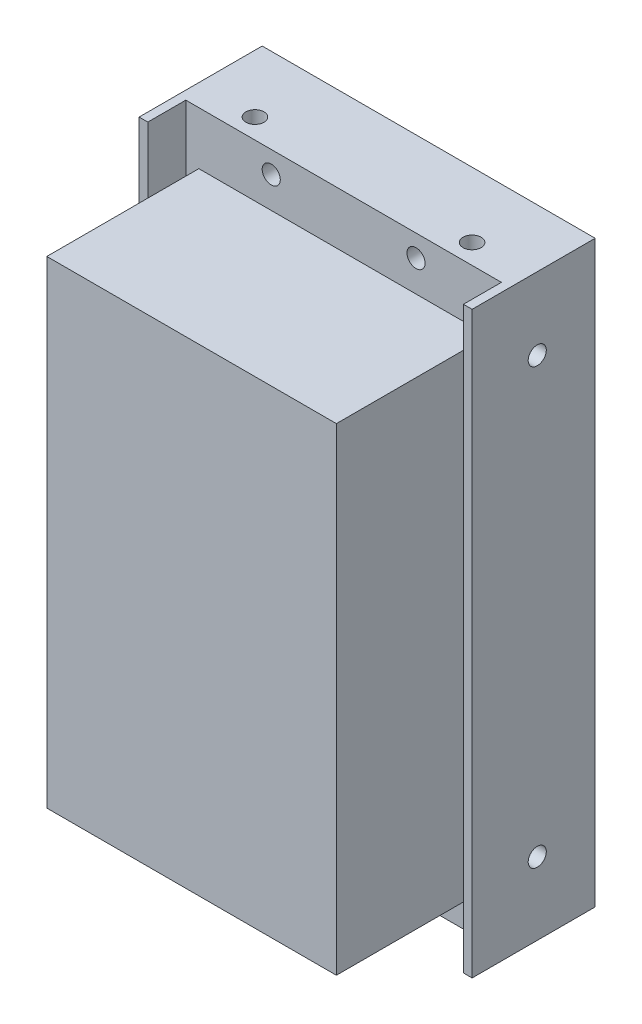
from build123d import *

# Parameters (mm, degrees)
SKETCH1_W                     = 46
SKETCH1_H                     = 11.75
BOSS_EXTRUDE1_DEPTH           = 80
SKETCH2_W                     = 1.2
SKETCH2_H                     = 5.25
BOSS_EXTRUDE2_DEPTH           = 80
SKETCH3_W                     = 40
SKETCH3_H                     = 66
CIRCUIT_BOARD_CLEARANCE_DEPTH = 21
M3X0_5_TAPPED_HOLE1_D         = 2.5
M3X0_5_TAPPED_HOLE2_D         = 2.5
M3X0_5_TAPPED_HOLE2_DEPTH     = 5
M3X0_5_TAPPED_HOLE2_TIP       = 0.751075774
M3X0_5_TAPPED_HOLE3_D         = 2.5


with BuildPart() as part:
    # Sketch1 → Boss-Extrude1 (new body)
    with BuildSketch(Plane(origin=(0, 0, 0), x_dir=(1, 0, 0), z_dir=(0, 1, 0))):
        with Locations((0, 5.875)):
            Rectangle(SKETCH1_W, SKETCH1_H)
    extrude(amount=BOSS_EXTRUDE1_DEPTH)

    # Sketch2 → Boss-Extrude2 (add)
    with BuildSketch(Plane(origin=(0, 0, 0), x_dir=(1, 0, 0), z_dir=(0, 1, 0))):
        with Locations((-22.4, -2.625)):
            Rectangle(SKETCH2_W, SKETCH2_H)
        with Locations((22.4, -2.625)):
            Rectangle(SKETCH2_W, SKETCH2_H)
    extrude(amount=BOSS_EXTRUDE2_DEPTH)

    # Sketch3 → Circuit Board clearance (add)
    with BuildSketch(Plane.XY):
        with Locations((0, 39.7)):
            Rectangle(SKETCH3_W, SKETCH3_H)
    extrude(amount=CIRCUIT_BOARD_CLEARANCE_DEPTH)

    # M3x0.5 Tapped Hole1 (through all)
    with Locations(Plane.XY):
        with Locations((-10, 77), (10, 77), (-10, 3), (10, 3)):
            Hole(M3X0_5_TAPPED_HOLE1_D / 2)

    # M3x0.5 Tapped Hole2
    with Locations(Plane(origin=(0, 80, 0), x_dir=(1, 0, 0), z_dir=(0, 1, 0))):
        with Locations((-15, 2.75), (15, 2.75)):
            Hole(M3X0_5_TAPPED_HOLE2_D / 2, depth=M3X0_5_TAPPED_HOLE2_DEPTH)
            with Locations((0, 0, -(M3X0_5_TAPPED_HOLE2_DEPTH + M3X0_5_TAPPED_HOLE2_TIP / 2))):  # 118° drill point
                Cone(0, M3X0_5_TAPPED_HOLE2_D / 2, M3X0_5_TAPPED_HOLE2_TIP, mode=Mode.SUBTRACT)

    # M3x0.5 Tapped Hole3 (through all)
    with Locations(Plane(origin=(23, 0, 0), x_dir=(0, 0, -1), z_dir=(1, 0, 0))):
        with Locations((3.75, 70), (3.75, 10)):
            Hole(M3X0_5_TAPPED_HOLE3_D / 2)


solid = part.part
